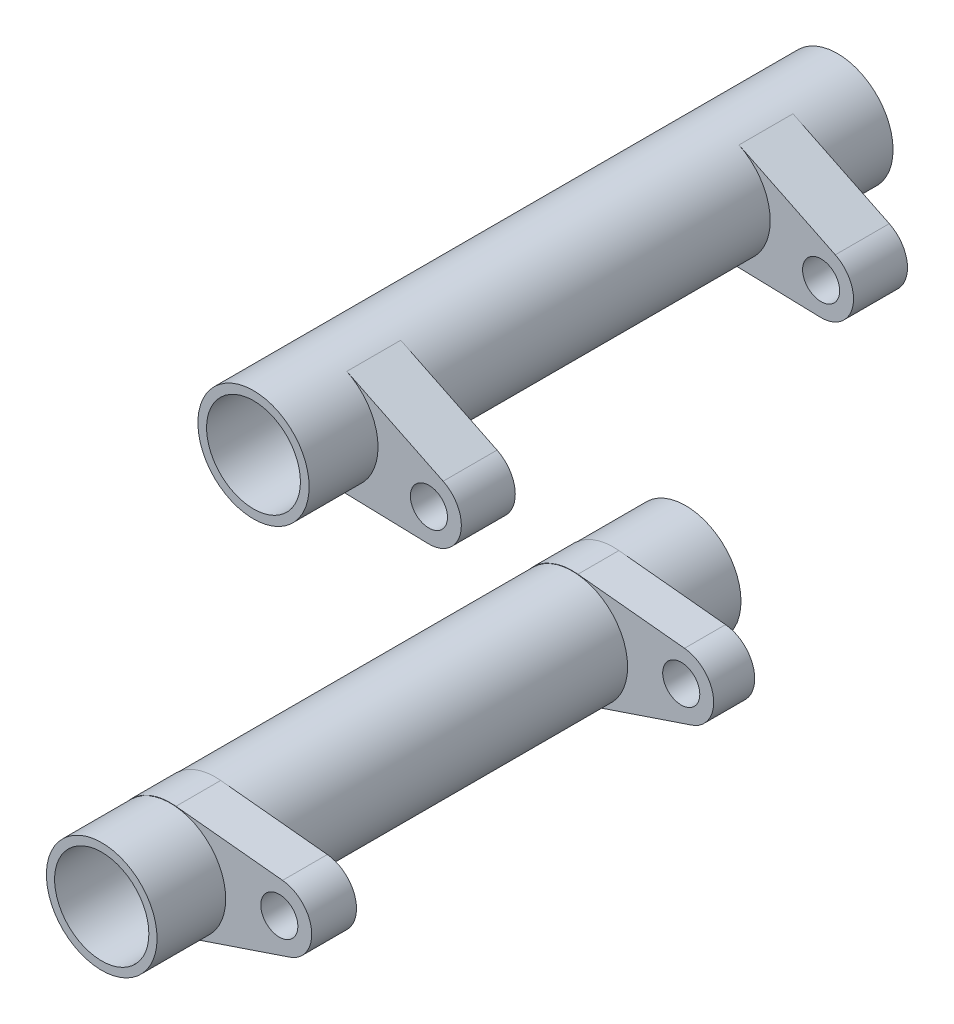
from build123d import *

# Parameters (mm, degrees)
BOSS_EXTRUDE1_DEPTH        = 25
BOSS_EXTRUDE1_DEPTH_BACK   = 25
SKETCH1_R                  = 1.5875
BOSS_EXTRUDE1_2_DEPTH      = 25
BOSS_EXTRUDE1_2_DEPTH_BACK = 25
SKETCH2_W                  = 30.585034638
SKETCH2_H                  = 9.810796571
SKETCH2_W_2                = 15.470183673
SKETCH2_W_3                = 13.851963624
SKETCH2_W_4                = 109.14073621
SKETCH2_H_2                = 4.034989958
SKETCH3_W                  = 28.963004802
SKETCH3_H                  = 14.709213774
SKETCH3_W_2                = 10.915618027
SKETCH3_W_3                = 10.243887687
SKETCH3_W_4                = 54.667422542
SKETCH3_H_2                = 4.017882111


with BuildPart() as part:
    # Sketch1 → Boss-Extrude1 (new, two sides: drawn at the far end of the back side and taken through both)
    with BuildSketch(Plane.XY.offset(-BOSS_EXTRUDE1_DEPTH_BACK)):
        with BuildLine():
            Line((9.61151388, 3.811971952), (0.480629395, 4.738185479))
            ThreePointArc((0.480629395, 4.738185479), (-4.732630614, -0.532553957), (1.521633661, -4.512874611))
            Line((1.521633661, -4.512874611), (10.21832503, -1.580557747))
            ThreePointArc((10.21832503, -1.580557747), (12.090045273, 1.36046989), (9.61151388, 3.811971952))
        make_face()
        with Locations((9.331350497, 1.050039193)):
            Circle(SKETCH1_R, mode=Mode.SUBTRACT)
    extrude(amount=BOSS_EXTRUDE1_DEPTH + BOSS_EXTRUDE1_DEPTH_BACK)

    # Sketch2 → Cut-Revolve1 (revolve, cut)
    with BuildSketch(Plane(origin=(0, 0, 0), x_dir=(0, 0, -1), z_dir=(1, 0, 0))):
        with Locations((0, 9.643583765)):
            Rectangle(SKETCH2_W, SKETCH2_H)
        with Locations((-26.860610177, 9.643583765)):
            Rectangle(SKETCH2_W_2, SKETCH2_H)
        with Locations((25.731541433, 9.643583765)):
            Rectangle(SKETCH2_W_3, SKETCH2_H)
        with Locations((0, 2.017494979)):
            Rectangle(SKETCH2_W_4, SKETCH2_H_2)
    revolve(axis=Axis((0, 0, 35.414629517), (0, 0, -1)), mode=Mode.SUBTRACT)


with BuildPart() as body_2:
    # Sketch1 → Boss-Extrude1 2 (new, two sides: drawn at the far end of the back side and taken through both)
    with BuildSketch(Plane.XY.offset(-BOSS_EXTRUDE1_2_DEPTH_BACK)):
        with BuildLine():
            Line((23.333418199, 40.257686297), (15.084349744, 44.28059477))
            ThreePointArc((15.084349744, 44.28059477), (8.371465163, 41.134811127), (12.866089587, 35.239293727))
            Line((12.866089587, 35.239293727), (22.040373547, 34.987427114))
            ThreePointArc((22.040373547, 34.987427114), (24.812702769, 37.100995404), (23.333418199, 40.257686297))
        make_face()
        with Locations((22.11655879, 37.762487454)):
            Circle(SKETCH1_R, mode=Mode.SUBTRACT)
    extrude(amount=BOSS_EXTRUDE1_2_DEPTH + BOSS_EXTRUDE1_2_DEPTH_BACK)

    # Sketch3 → Cut-Revolve2 (revolve, cut)
    with BuildSketch(Plane(origin=(12.996787849, 0, 0), x_dir=(0, 0, -1), z_dir=(1, 0, 0))):
        with Locations((0, 52.117106887)):
            Rectangle(SKETCH3_W, SKETCH3_H)
        with Locations((-24.557457504, 52.117106887)):
            Rectangle(SKETCH3_W_2, SKETCH3_H)
        with Locations((24.226958448, 52.117106887)):
            Rectangle(SKETCH3_W_3, SKETCH3_H)
        with Locations((0, 42.008941056)):
            Rectangle(SKETCH3_W_4, SKETCH3_H_2)
    revolve(axis=Axis((12.996787849, 40, 0), (0, 0, -1)), mode=Mode.SUBTRACT)


solid = Compound([part.part, body_2.part])
